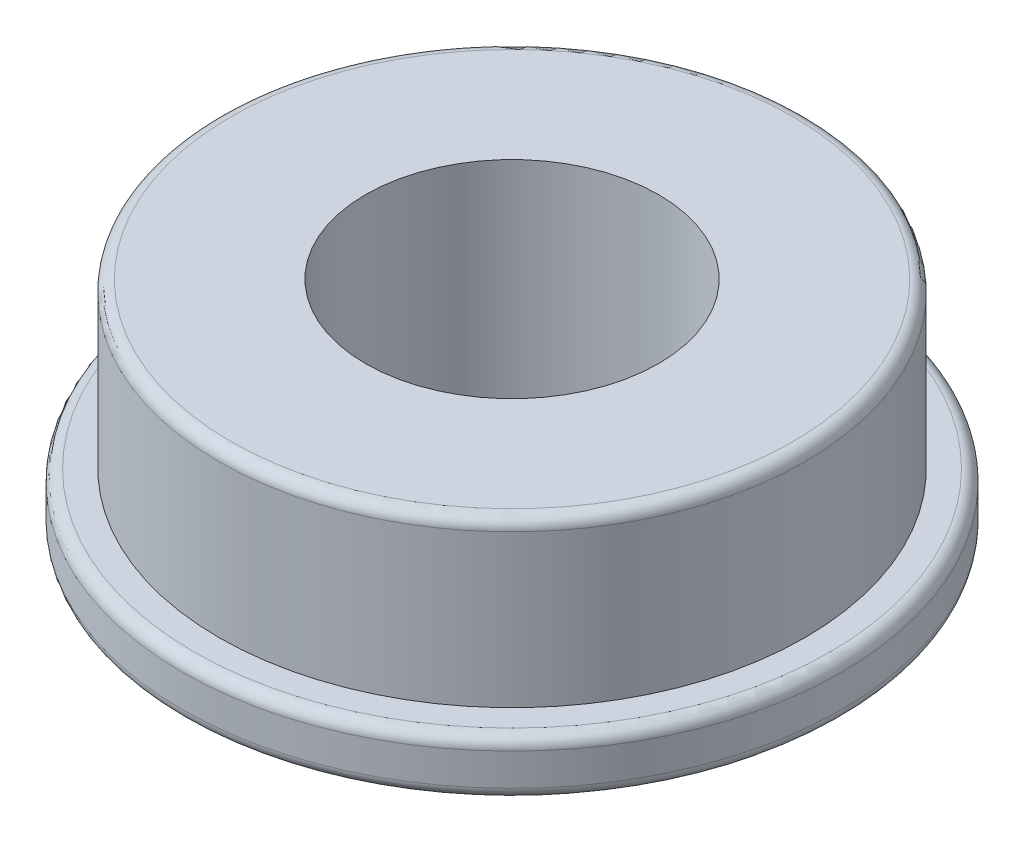
from build123d import *

# Parameters (mm, degrees)
SKETCH1_R           = 6.35
SKETCH1_R_2         = 3.175
BOSS_EXTRUDE1_DEPTH = 4.7625
SKETCH1_3_R         = 7.14375
SKETCH1_3_R_2       = 6.35
BOSS_EXTRUDE2_DEPTH = 1.2065
FILLET1_R           = 0.254


with BuildPart() as part:
    # Sketch1 → Boss-Extrude1 (new body)
    with BuildSketch(Plane(origin=(0, 0, 0), x_dir=(1, 0, 0), z_dir=(0, 1, 0))):
        Circle(SKETCH1_R)
        Circle(SKETCH1_R_2, mode=Mode.SUBTRACT)
    extrude(amount=BOSS_EXTRUDE1_DEPTH)

    # Sketch1_3 → Boss-Extrude2 (add)
    with BuildSketch(Plane(origin=(0, 0, 0), x_dir=(1, 0, 0), z_dir=(0, 1, 0))):
        Circle(SKETCH1_3_R)
        Circle(SKETCH1_3_R_2, mode=Mode.SUBTRACT)
    extrude(amount=BOSS_EXTRUDE2_DEPTH)

    # Fillet1
    fillet1_edges = [part.edges().sort_by_distance(p)[0] for p in [
        (-7.14375, 0, 0),
        (-7.14375, 1.2065, 0),
        (-6.35, 4.7625, 0),
    ]]
    fillet(fillet1_edges, radius=FILLET1_R)


solid = part.part
